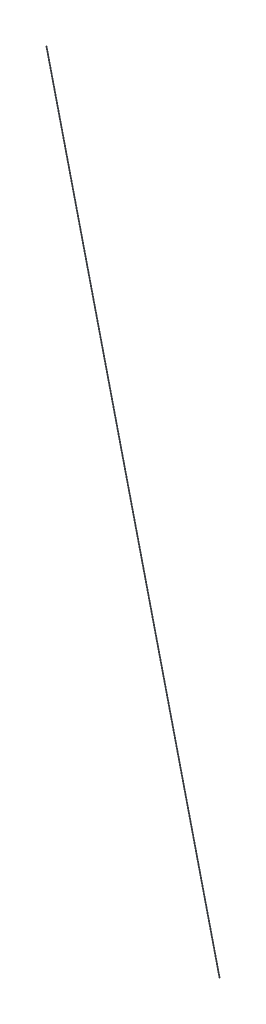
from build123d import *

# Parameters (mm, degrees)
SWEEP_3_PROFILE_R = 0.5


with BuildPart() as part:
    # 扫描3: sweep along a path in 草图3
    with BuildLine(Plane.XY) as sweep_3_path:
        Line((307.5, 0), (0, 1279.38))
    # 扫描3 profile (on start of the path) → 扫描3 (sweep)
    with BuildSketch(Plane(origin=(307.5, 0, 0), x_dir=(0.972309847, 0.233695445, 0), z_dir=(-0.233695445, 0.972309847, 0))):
        Circle(SWEEP_3_PROFILE_R)
    sweep(path=sweep_3_path.line)


solid = part.part
